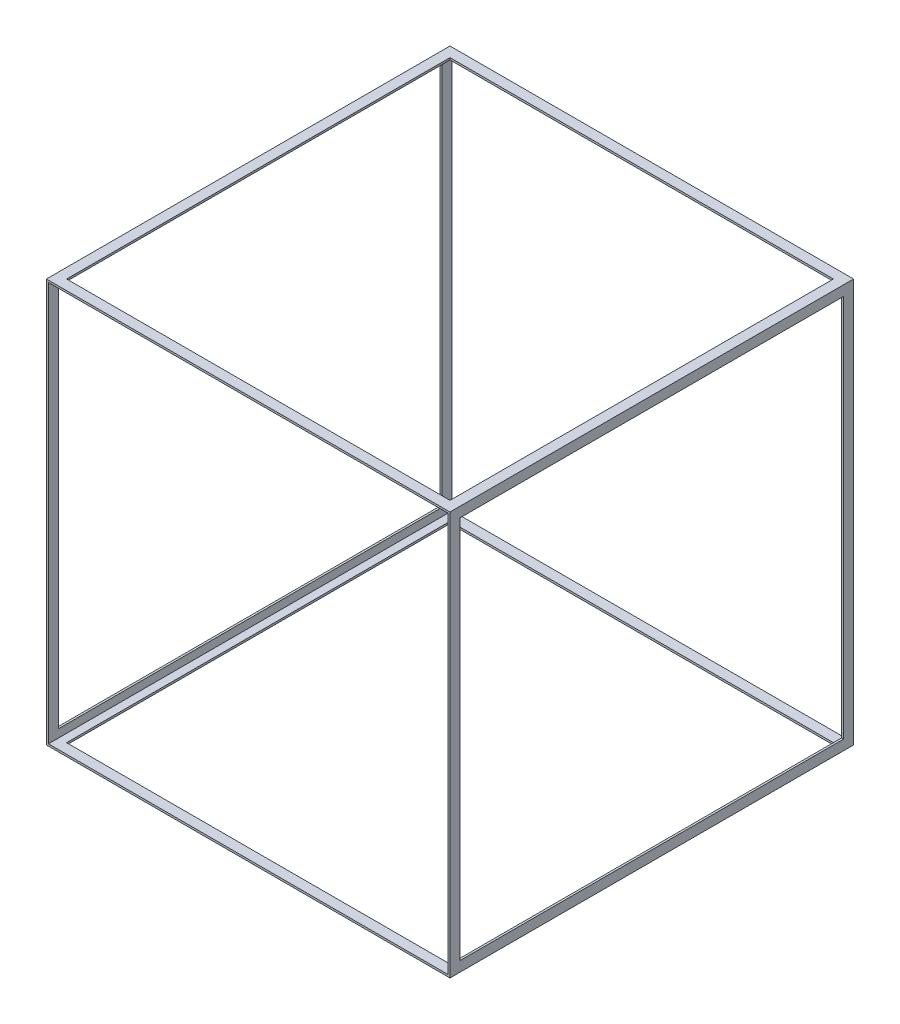
from build123d import *

# Parameters (mm, degrees)
SKETCH3_W               = 20000
SKETCH3_H               = 20000
SKETCH3_W_2             = 19800
SKETCH3_H_2             = 19800
BOSS_EXTRUDE1_DEPTH     = 20000
SKETCH4_W               = 19000
SKETCH4_H               = 19000
CUT_EXTRUDE1_DEPTH      = 1
CUT_EXTRUDE1_DEPTH_BACK = 20001
SKETCH5_W               = 19000
SKETCH5_H               = 19000
CUT_EXTRUDE2_DEPTH      = 20000


with BuildPart() as part:
    # Sketch3 → Boss-Extrude1 (new body)
    with BuildSketch(Plane.XY):
        with Locations((10000, 10000)):
            Rectangle(SKETCH3_W, SKETCH3_H)
        with Locations((10000, 10000)):
            Rectangle(SKETCH3_W_2, SKETCH3_H_2, mode=Mode.SUBTRACT)
    extrude(amount=BOSS_EXTRUDE1_DEPTH)

    # Sketch4 → Cut-Extrude1 (cut, two sides)
    with BuildSketch(Plane.ZY) as cut_extrude1_sk:
        with Locations((10000, 10000)):
            Rectangle(SKETCH4_W, SKETCH4_H)
    extrude(amount=CUT_EXTRUDE1_DEPTH, mode=Mode.SUBTRACT)
    extrude(cut_extrude1_sk.sketch, amount=-CUT_EXTRUDE1_DEPTH_BACK, mode=Mode.SUBTRACT)

    # Sketch5 → Cut-Extrude2 (cut)
    with BuildSketch(Plane.XZ):
        with Locations((10000, 10000)):
            Rectangle(SKETCH5_W, SKETCH5_H)
    extrude(amount=-CUT_EXTRUDE2_DEPTH, mode=Mode.SUBTRACT)


solid = part.part
